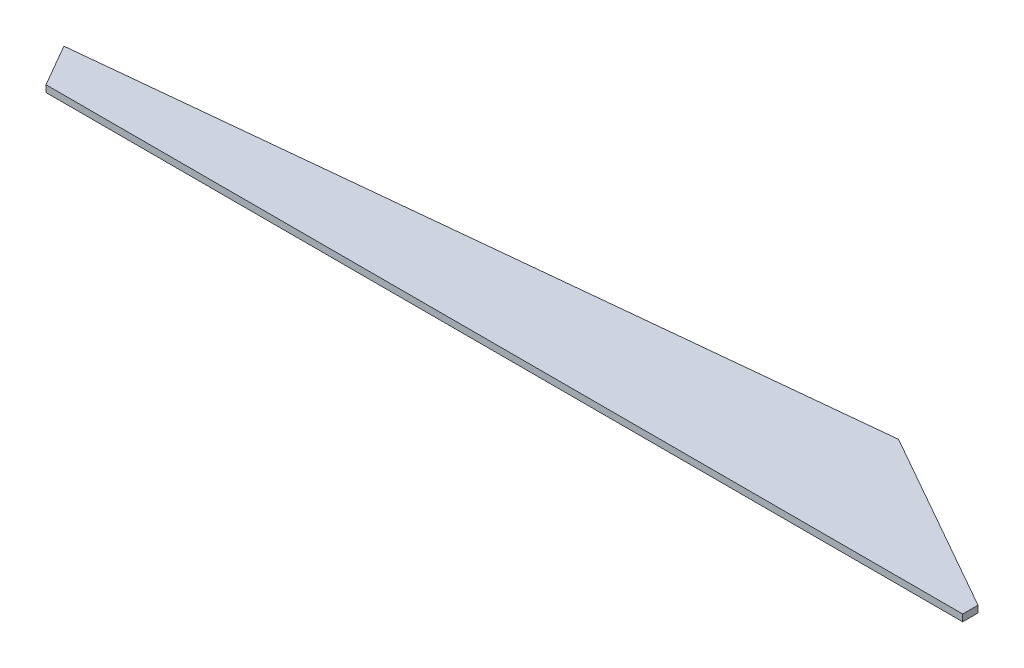
from build123d import *

# Parameters (mm, degrees)
BOSS_EXTRUDE1_DEPTH = 50


with BuildPart() as part:
    # Sketch1 → Boss-Extrude1 (new body)
    with BuildSketch(Plane(origin=(0, 0, 0), x_dir=(1, 0, 0), z_dir=(0, 1, 0))):
        Polygon((-1350, 0), (0, 0), (0, 112.5), (-1350, 877.5), align=None)
        Polygon((-6750, 0), (-1350, 0), (-1350, 877.5), (-6930, 311.769145362), align=None)
    extrude(amount=BOSS_EXTRUDE1_DEPTH)


solid = part.part
